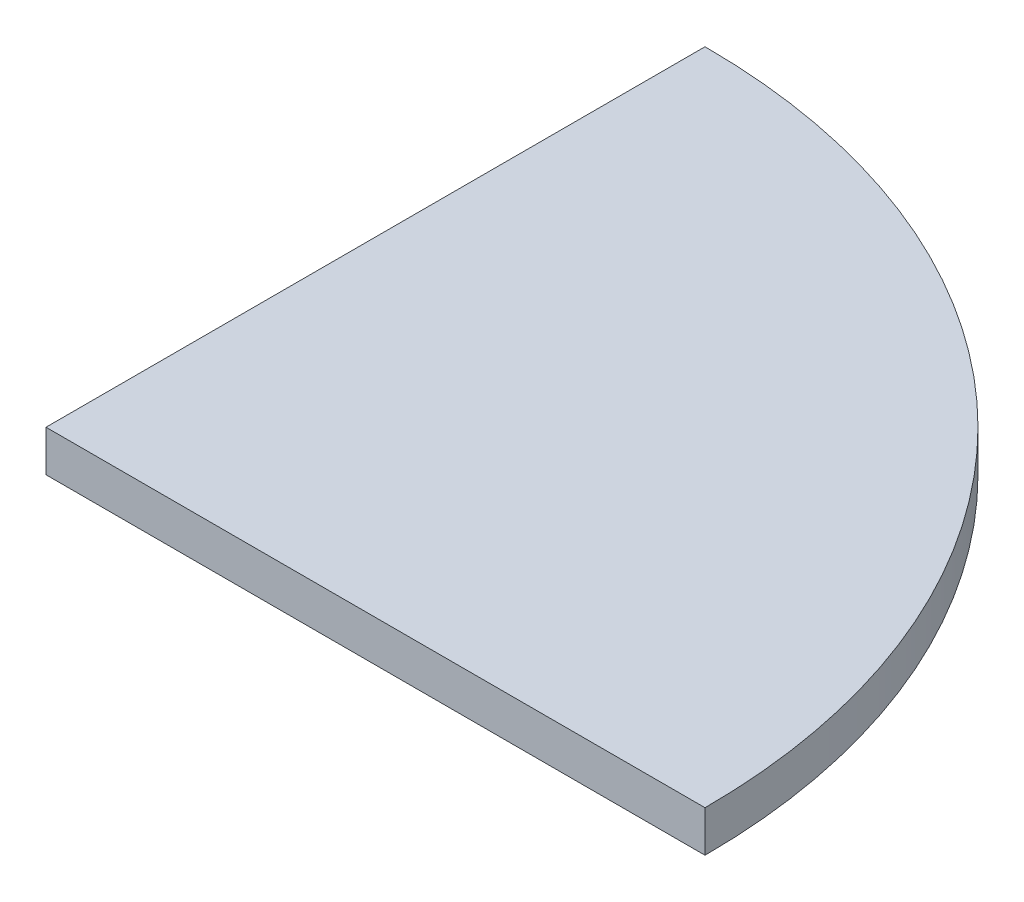
from build123d import *

# Parameters (mm, degrees)
BOSS_EXTRUDE1_DEPTH = 19.05


with BuildPart() as part:
    # Sketch1 → Boss-Extrude1 (new body)
    with BuildSketch(Plane(origin=(0, 0, 0), x_dir=(1, 0, 0), z_dir=(0, 1, 0))):
        with BuildLine():
            Line((0, 304.8), (0, 0))
            Line((0, 0), (304.8, 0))
            ThreePointArc((304.8, 0), (215.526146906, 215.526146906), (0, 304.8))
        make_face()
    extrude(amount=BOSS_EXTRUDE1_DEPTH)


solid = part.part
